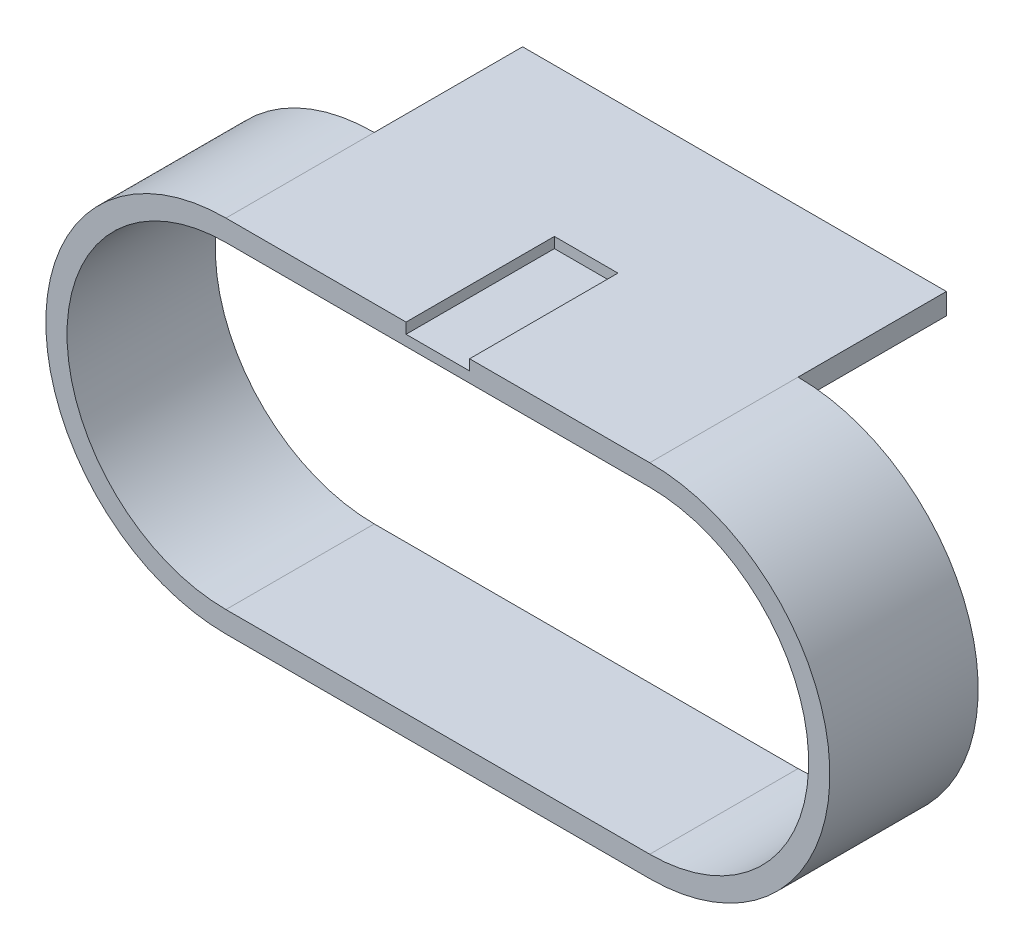
from build123d import *

# Parameters (mm, degrees)
BOSS_EXTRUDE1_DEPTH            = 8.89
CUT_EXTRUDE1_REACH             = 10.89
SKETCH3_W                      = 7.62
SKETCH3_H                      = 2.54
CUT_EXTRUDE1_DIRECTION_2_REACH = 10.89
SKETCH4_W                      = 50.8
SKETCH4_H                      = 2.54
BOSS_EXTRUDE2_DEPTH            = 17.78


with BuildPart() as part:
    # Sketch2 → Boss-Extrude1 (new body, symmetric)
    with BuildSketch(Plane.XY):
        with BuildLine():
            Line((-25.4, 21.59), (25.4, 21.59))
            ThreePointArc((25.4, 21.59), (46.99, 0), (25.4, -21.59))
            Line((25.4, -21.59), (-25.4, -21.59))
            ThreePointArc((-25.4, -21.59), (-46.99, 0), (-25.4, 21.59))
        make_face()
        with BuildLine():
            Line((-25.4, 19.05), (25.4, 19.05))
            ThreePointArc((25.4, 19.05), (44.45, 0), (25.4, -19.05))
            Line((25.4, -19.05), (-25.4, -19.05))
            ThreePointArc((-25.4, -19.05), (-44.45, 0), (-25.4, 19.05))
        make_face(mode=Mode.SUBTRACT)
    extrude(amount=BOSS_EXTRUDE1_DEPTH, both=True)

    # Sketch3 → Cut-Extrude1 (cut, up to next)
    with BuildSketch(Plane.XY, mode=Mode.PRIVATE) as cut_extrude1_sk1:
        with Locations((0, 21.59)):
            Rectangle(SKETCH3_W, SKETCH3_H)
    cut_extrude1_tool1 = extrude(cut_extrude1_sk1.sketch, amount=-CUT_EXTRUDE1_REACH, mode=Mode.PRIVATE) & part.part
    add(cut_extrude1_tool1.solids().sort_by_distance((0, 21.59, 0))[0], mode=Mode.SUBTRACT)

    # Sketch3 → Cut-Extrude1 direction 2 (cut, up to next)
    with BuildSketch(Plane.XY, mode=Mode.PRIVATE) as cut_extrude1_direction_2_sk1:
        with Locations((0, 21.59)):
            Rectangle(SKETCH3_W, SKETCH3_H)
    cut_extrude1_direction_2_tool1 = extrude(cut_extrude1_direction_2_sk1.sketch, amount=CUT_EXTRUDE1_DIRECTION_2_REACH, mode=Mode.PRIVATE) & part.part
    add(cut_extrude1_direction_2_tool1.solids().sort_by_distance((0, 21.59, 0))[0], mode=Mode.SUBTRACT)

    # Sketch4 → Boss-Extrude2 (add)
    with BuildSketch(Plane(origin=(0, 0, -8.89), x_dir=(-1, 0, 0), z_dir=(0, 0, -1))):
        with Locations((0, 20.32)):
            Rectangle(SKETCH4_W, SKETCH4_H)
    extrude(amount=BOSS_EXTRUDE2_DEPTH)


solid = part.part
